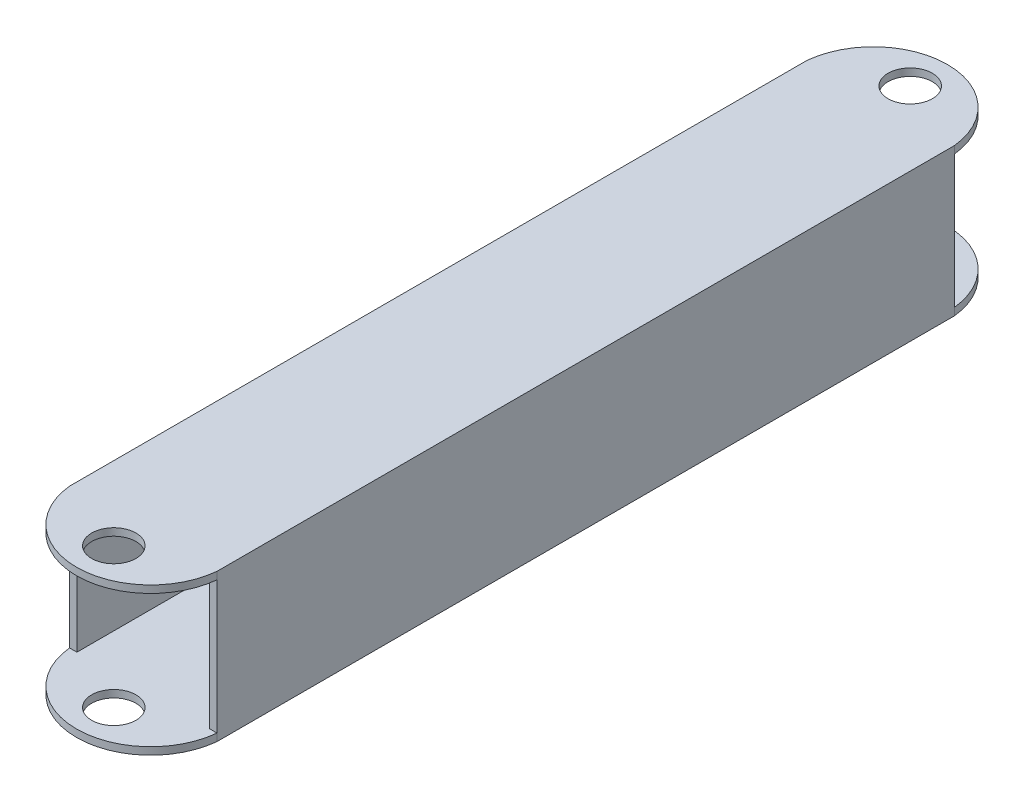
from build123d import *

# Parameters (mm, degrees)
SKETCH1_W               = 20
SKETCH1_H               = 20
SKETCH1_W_2             = 18
SKETCH1_H_2             = 18
BOSS_EXTRUDE1_DEPTH     = 50
BOSS_EXTRUDE2_START     = -1
SKETCH2_R               = 3
BOSS_EXTRUDE2_DEPTH     = 1
MIRROR2_START           = -1
MIRROR2_COPY_1_SKETCH_R = 3
MIRROR2_COPY_1_DEPTH    = 1


with BuildPart() as part:
    # Sketch1 → Boss-Extrude1 (new body, symmetric)
    with BuildSketch(Plane.XY):
        Rectangle(SKETCH1_W, SKETCH1_H)
        Rectangle(SKETCH1_W_2, SKETCH1_H_2, mode=Mode.SUBTRACT)
    extrude(amount=BOSS_EXTRUDE1_DEPTH, both=True)

    # Sketch2 → Boss-Extrude2 (add)
    with BuildSketch(Plane.XZ.offset(10).offset(BOSS_EXTRUDE2_START)):
        with BuildLine():
            Line((-10, 50), (10, 50))
            ThreePointArc((10, 50), (0, 59.049875621), (-10, 50))
        make_face()
        with Locations((0, 54)):
            Circle(SKETCH2_R, mode=Mode.SUBTRACT)
    boss_extrude2 = extrude(amount=BOSS_EXTRUDE2_DEPTH)

    # Mirror1: Boss-Extrude2 across plane
    add(boss_extrude2.mirror(Plane.XY))

    # Mirror2: Boss-Extrude2 across plane
    add(boss_extrude2.mirror(Plane.ZX))

    # Mirror2 copy 1 sketch → Mirror2 copy 1 (add)
    with BuildSketch(Plane(origin=(0, 10, 0), x_dir=(1, 0, 0), z_dir=(0, 1, 0)).offset(MIRROR2_START)):
        with BuildLine():
            Line((-10, 50), (10, 50))
            ThreePointArc((10, 50), (0, 59.049875621), (-10, 50))
        make_face()
        with Locations((0, 54)):
            Circle(MIRROR2_COPY_1_SKETCH_R, mode=Mode.SUBTRACT)
    extrude(amount=MIRROR2_COPY_1_DEPTH)


solid = part.part
